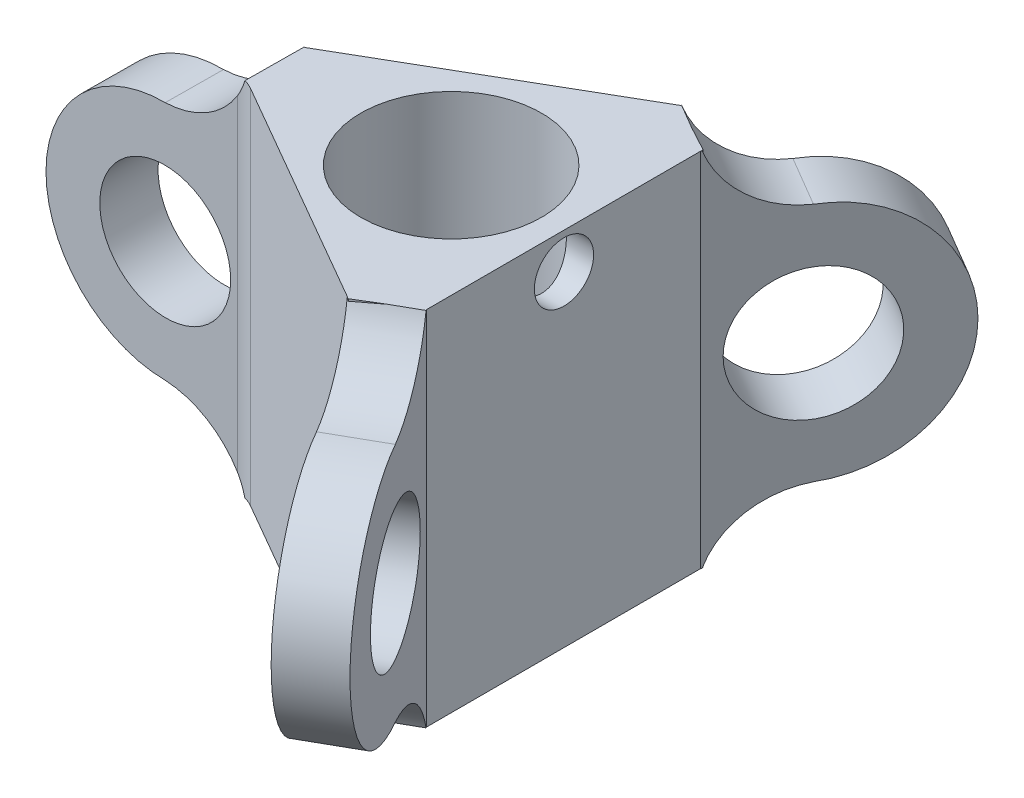
from build123d import *

# Parameters (mm, degrees)
BOSS_EXTRUDE1_DEPTH = 25.4
SKETCH3_R           = 6.35
CUT_EXTRUDE1_DEPTH  = 12.7
SKETCH4_R           = 3.556
CUT_EXTRUDE2_DEPTH  = 12.7
SKETCH11_R          = 4.6355
BOSS_EXTRUDE3_DEPTH = 2.032
CIRPATTERN1_COUNT   = 3
SKETCH12_R          = 2.0828
CUT_EXTRUDE4_DEPTH  = 2.9718
FILLET3_R           = 2.54


with BuildPart() as part:
    # Sketch1 → Boss-Extrude1 (new body)
    with BuildSketch(Plane(origin=(0, 0, 0), x_dir=(1, 0, 0), z_dir=(0, 1, 0))):
        Polygon((7.906621038, 9.792659833), (7.917579369, -9.673383406), (4.508232527, -11.732623201), (-12.391554014, -1.98820766), (-12.35878698, 1.994487054), (4.399412926, 11.682420986), align=None)
    extrude(amount=BOSS_EXTRUDE1_DEPTH)

    # Sketch3 → Cut-Extrude1 (cut)
    with BuildSketch(Plane(origin=(0, 25.4, 0), x_dir=(1, 0, 0), z_dir=(0, 1, 0))):
        Circle(SKETCH3_R)
    extrude(amount=-CUT_EXTRUDE1_DEPTH, mode=Mode.SUBTRACT)

    # Sketch4 → Cut-Extrude2 (cut)
    with BuildSketch(Plane.XZ):
        Circle(SKETCH4_R)
    extrude(amount=-CUT_EXTRUDE2_DEPTH, mode=Mode.SUBTRACT)

    # Sketch11 → Boss-Extrude3 (add, symmetric)
    with BuildSketch(Plane(origin=(-0.000811781, 0, 0.098668517), x_dir=(0.9999661570516756, 0, 0.008227074285784747), z_dir=(-0.008227074285784747, 0, 0.9999661570516756))):
        with BuildLine():
            Line((-12.151651157, 25.4), (-12.151651157, 0))
            Line((-12.151651157, 0), (-12.374777516, 0))
            ThreePointArc((-12.374777516, 0), (-14.579369049, 3.004291223), (-18.089777516, 4.2545))
            ThreePointArc((-18.089777516, 4.2545), (-26.535277516, 12.7), (-18.089777516, 21.1455))
            ThreePointArc((-18.089777516, 21.1455), (-14.579369049, 22.395708777), (-12.374777516, 25.4))
            Line((-12.374777516, 25.4), (-12.151651157, 25.4))
        make_face()
        with Locations((-18.089777516, 12.7)):
            Circle(SKETCH11_R, mode=Mode.SUBTRACT)
    boss_extrude3 = extrude(amount=BOSS_EXTRUDE3_DEPTH, both=True)

    # CirPattern1: Boss-Extrude3 ×3 about axis
    cirpattern1_axis = Axis((0, 12.7, 0), (0, 1, 0))
    for i in range(1, CIRPATTERN1_COUNT):
        add(boss_extrude3.rotate(cirpattern1_axis, i * 360 / CIRPATTERN1_COUNT))

    # Sketch12 → Cut-Extrude4 (cut)
    with BuildSketch(Plane(origin=(7.912131269, 0, -0.004454103), x_dir=(-0.0005629459184425108, 0, -0.9999998415459339), z_dir=(0.9999998415459339, 0, -0.0005629459184425108))):
        with Locations((0.010106248, 22.86)):
            Circle(SKETCH12_R)
    extrude(amount=-CUT_EXTRUDE4_DEPTH, mode=Mode.SUBTRACT)

    # Fillet3
    fillet3_edges = [part.edges().sort_by_distance(p)[0] for p in [
        (-12.320145535, 12.7, 2.029381784),
    ]]
    fillet(fillet3_edges, radius=FILLET3_R)


solid = part.part
